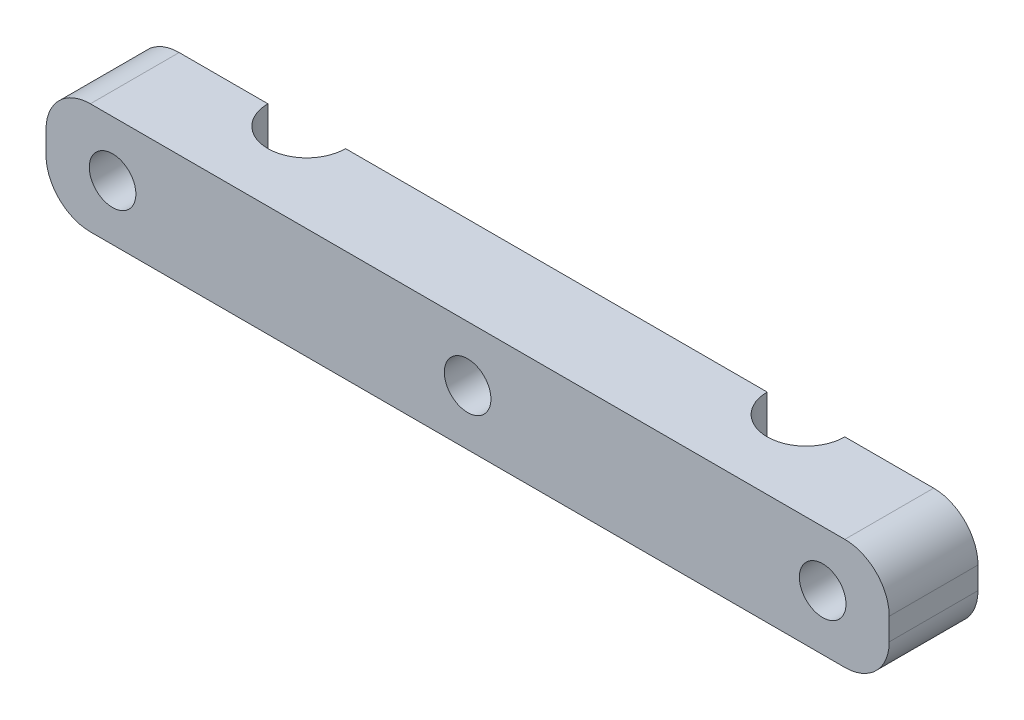
from build123d import *

# Parameters (mm, degrees)
BOSS_EXTRUDE1_DEPTH = 10
SKETCH2_R           = 2.1
CUT_EXTRUDE1_DEPTH  = 9
FILLET1_R           = 4


with BuildPart() as part:
    # Sketch1 → Boss-Extrude1 (new body)
    with BuildSketch(Plane(origin=(0, 0, 0), x_dir=(1, 0, 0), z_dir=(0, 1, 0))):
        with BuildLine():
            Line((-38, -8), (38, -8))
            Line((38, -8), (38, 0))
            Line((38, 0), (26, 0))
            ThreePointArc((26, 0), (22.5, -3.5), (19, 0))
            Line((19, 0), (-19, 0))
            ThreePointArc((-19, 0), (-22.5, -3.5), (-26, 0))
            Line((-26, 0), (-38, 0))
            Line((-38, 0), (-38, -8))
        make_face()
    extrude(amount=BOSS_EXTRUDE1_DEPTH)

    # Sketch2 → Cut-Extrude1 (cut, through all)
    with BuildSketch(Plane(origin=(0, 0, 0), x_dir=(-1, 0, 0), z_dir=(0, 0, -1))):
        with Locations((32, 5)):
            Circle(SKETCH2_R)
        with Locations((-32, 5)):
            Circle(SKETCH2_R)
        with Locations((0, 5)):
            Circle(SKETCH2_R)
    extrude(amount=-CUT_EXTRUDE1_DEPTH, mode=Mode.SUBTRACT)

    # Fillet1
    fillet1_edges = [part.edges().sort_by_distance(p)[0] for p in [
        (38, 0, 4),
        (-38, 0, 4),
        (38, 10, 4),
        (-38, 10, 4),
    ]]
    fillet(fillet1_edges, radius=FILLET1_R)


solid = part.part
